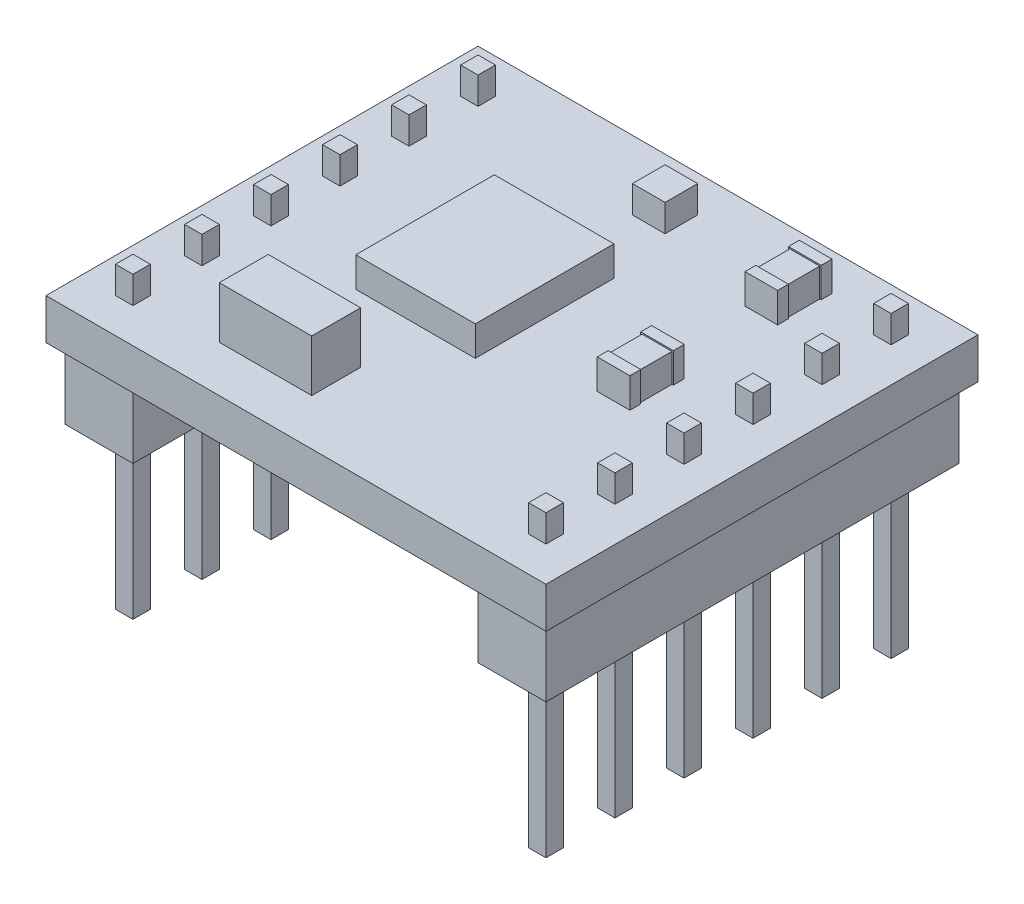
from build123d import *

# Parameters (mm, degrees)
SKETCH1_W           = 18.4
SKETCH1_H           = 15.9
BOSS_EXTRUDE1_DEPTH = 1.5
SKETCH2_W           = 2.5
SKETCH2_H           = 15.2
BOSS_EXTRUDE2_DEPTH = 2.6
BOSS_EXTRUDE3_START = -5.1
SKETCH3_W           = 0.64
SKETCH3_H           = 0.64
BOSS_EXTRUDE3_DEPTH = 11
SKETCH5_W           = 4.4
SKETCH5_H           = 5.1
SKETCH5_W_2         = 1.2
SKETCH5_H_2         = 2
BOSS_EXTRUDE4_DEPTH = 1.1
SKETCH6_W           = 1.2
SKETCH6_H           = 1.2
BOSS_EXTRUDE5_DEPTH = 1
SKETCH7_W           = 3.4
SKETCH7_H           = 1.8
BOSS_EXTRUDE6_DEPTH = 1.9
SKETCH8_W           = 1.2
SKETCH8_H           = 1.2
CUT_EXTRUDE1_DEPTH  = 0.05
SKETCH9_W           = 1.2
SKETCH9_H           = 1.05
CUT_EXTRUDE2_DEPTH  = 0.05
SKETCH10_W          = 1.2
SKETCH10_H          = 1.05
CUT_EXTRUDE3_DEPTH  = 0.05


with BuildPart() as part:
    # Sketch1 → Boss-Extrude1 (new body)
    with BuildSketch(Plane(origin=(0, 0, 0), x_dir=(1, 0, 0), z_dir=(0, 1, 0))):
        Rectangle(SKETCH1_W, SKETCH1_H)
    extrude(amount=-BOSS_EXTRUDE1_DEPTH)

    # Sketch2 → Boss-Extrude2 (add)
    with BuildSketch(Plane.XZ.offset(1.5)):
        with Locations((-7.6, 0)):
            Rectangle(SKETCH2_W, SKETCH2_H)
    boss_extrude2 = extrude(amount=BOSS_EXTRUDE2_DEPTH)

    # Sketch3 → Boss-Extrude3 (add)
    with BuildSketch(Plane(origin=(0, -4.1, 0), x_dir=(-1, 0, 0), z_dir=(0, -1, 0)).offset(BOSS_EXTRUDE3_START)):
        with Locations((7.6, -6.35)):
            Rectangle(SKETCH3_W, SKETCH3_H)
        with Locations((7.6, -3.81)):
            Rectangle(SKETCH3_W, SKETCH3_H)
        with Locations((7.6, -1.27)):
            Rectangle(SKETCH3_W, SKETCH3_H)
        with Locations((7.6, 1.27)):
            Rectangle(SKETCH3_W, SKETCH3_H)
        with Locations((7.6, 6.35)):
            Rectangle(SKETCH3_W, SKETCH3_H)
        with Locations((7.6, 3.81)):
            Rectangle(SKETCH3_W, SKETCH3_H)
    boss_extrude3 = extrude(amount=BOSS_EXTRUDE3_DEPTH)

    # Mirror1: Boss-Extrude2, Boss-Extrude3 across plane
    add(boss_extrude2.mirror(Plane(origin=(0, 0, 0), x_dir=(0, 0, 1), z_dir=(1, 0, 0))))
    add(boss_extrude3.mirror(Plane(origin=(0, 0, 0), x_dir=(0, 0, 1), z_dir=(1, 0, 0))))

    # Sketch5 → Boss-Extrude4 (add)
    with BuildSketch(Plane(origin=(0, 0, 0), x_dir=(1, 0, 0), z_dir=(0, 1, 0))):
        with Locations((-1.5, 0.5)):
            Rectangle(SKETCH5_W, SKETCH5_H)
        with Locations((4.5979, 0.1395)):
            Rectangle(SKETCH5_W_2, SKETCH5_H_2)
        with Locations((4.5979, 5.5766)):
            Rectangle(SKETCH5_W_2, SKETCH5_H_2)
    extrude(amount=BOSS_EXTRUDE4_DEPTH)

    # Sketch6 → Boss-Extrude5 (add)
    with BuildSketch(Plane(origin=(0, 0, 0), x_dir=(1, 0, 0), z_dir=(0, 1, 0))):
        with Locations((-0.3788, 6.0122)):
            Rectangle(SKETCH6_W, SKETCH6_H)
    extrude(amount=BOSS_EXTRUDE5_DEPTH)

    # Sketch7 → Boss-Extrude6 (add)
    with BuildSketch(Plane(origin=(0, 0, 0), x_dir=(1, 0, 0), z_dir=(0, 1, 0))):
        with Locations((-2.8238, -5.3484)):
            Rectangle(SKETCH7_W, SKETCH7_H)
    extrude(amount=BOSS_EXTRUDE6_DEPTH)

    # Sketch8 → Cut-Extrude1 (cut)
    with BuildSketch(Plane(origin=(0, 1.1, 0), x_dir=(1, 0, 0), z_dir=(0, 1, 0))):
        with Locations((4.5979, 5.5766)):
            Rectangle(SKETCH8_W, SKETCH8_H)
        with Locations((4.5979, 0.1395)):
            Rectangle(SKETCH8_W, SKETCH8_H)
    extrude(amount=-CUT_EXTRUDE1_DEPTH, mode=Mode.SUBTRACT)

    # Sketch9 → Cut-Extrude2 (cut)
    with BuildSketch(Plane.ZY.offset(-3.9979)):
        with Locations((-0.1395, 0.525)):
            Rectangle(SKETCH9_W, SKETCH9_H)
        with Locations((-5.5766, 0.525)):
            Rectangle(SKETCH9_W, SKETCH9_H)
    extrude(amount=-CUT_EXTRUDE2_DEPTH, mode=Mode.SUBTRACT)

    # Sketch10 → Cut-Extrude3 (cut)
    with BuildSketch(Plane(origin=(5.1979, 0, 0), x_dir=(0, 0, -1), z_dir=(1, 0, 0))):
        with Locations((0.1395, 0.525)):
            Rectangle(SKETCH10_W, SKETCH10_H)
        with Locations((5.5766, 0.525)):
            Rectangle(SKETCH10_W, SKETCH10_H)
    extrude(amount=-CUT_EXTRUDE3_DEPTH, mode=Mode.SUBTRACT)


solid = part.part
